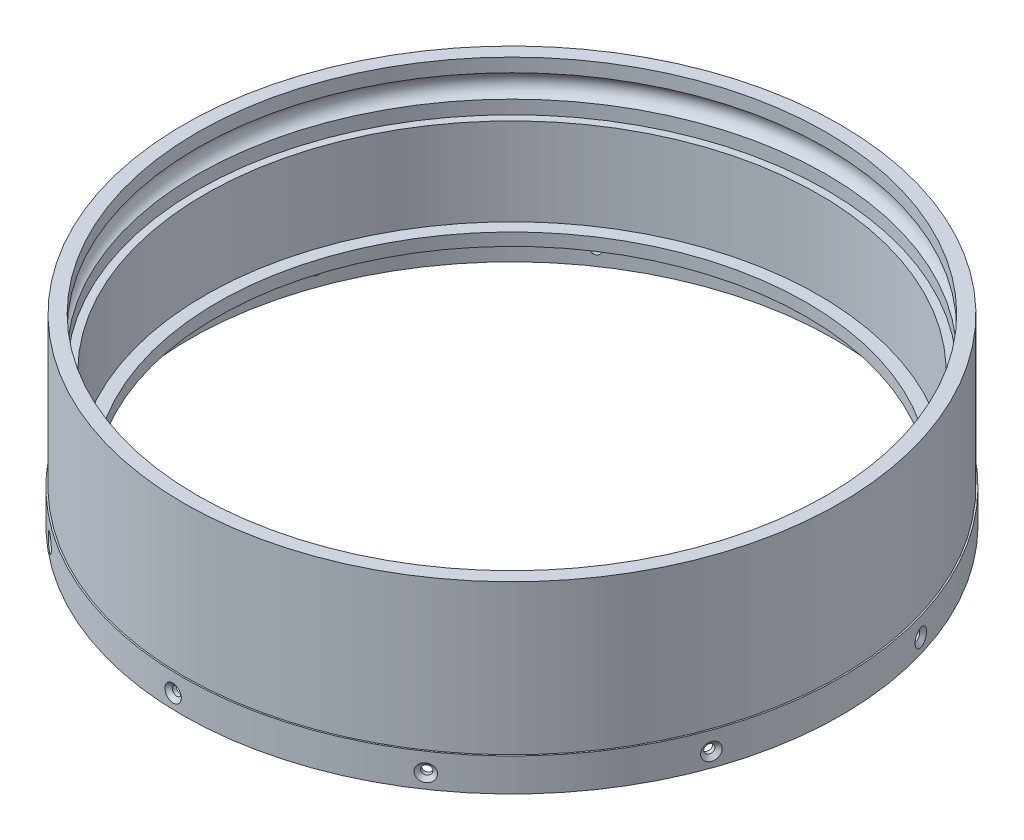
from build123d import *

# Parameters (mm, degrees)
CIRPATTERN1_COUNT = 10


with BuildPart() as part:
    # Sketch2 → Revolve1 (revolve)
    with BuildSketch(Plane(origin=(0, 0, 0), x_dir=(0, 0, -1), z_dir=(1, 0, 0))):
        with BuildLine():
            Line((79.99222, -2.192455674), (79.99222, -5.632520108))
            ThreePointArc((79.99222, -5.632520108), (81.89722, -8.542455674), (79.99222, -11.45239124))
            Line((79.99222, -11.45239124), (79.99222, -14.892455674))
            Line((79.99222, -14.892455674), (78.08722, -14.892455674))
            Line((78.08722, -14.892455674), (78.08722, -37.117455674))
            Line((78.08722, -37.117455674), (74.91222, -37.117455674))
            Line((74.91222, -37.117455674), (74.91222, -40.292455674))
            Line((74.91222, -40.292455674), (81.9531, -40.292455674))
            Line((81.9531, -40.292455674), (81.9531, -48.674455674))
            Line((81.9531, -48.674455674), (83.82, -48.674455674))
            Line((83.82, -48.674455674), (83.82, -40.292455674))
            Line((83.82, -40.292455674), (83.439, -40.292455674))
            Line((83.439, -40.292455674), (83.439, -2.192455674))
            Line((83.439, -2.192455674), (79.99222, -2.192455674))
        make_face()
    revolve(axis=Axis((0, 0, 0), (0, -1, 0)))

    # Sketch3 → CSK for #2 Flat Head Machine Screw (100)1 (revolve, cut)
    with BuildSketch(Plane(origin=(2.413258622, -45.008517513, -83.785252777), x_dir=(-0.999585454, 0, -0.028790964), z_dir=(0, 1, 0))):
        Polygon((0, 0), (0, 76.879152758), (1.1303, 76.2), (1.1303, 0.884494921), (2.1844, 0), align=None)
    csk_for_2_flat_head_machine_screw_100 = revolve(axis=Axis((2.596081245, -45.008517513, -90.132620411), (-0.028790964, 0, 0.999585454)), mode=Mode.SUBTRACT)

    # CirPattern1: CSK for #2 Flat Head Machine Screw (100)1 ×10 about axis
    cirpattern1_axis = Axis((0, 0, 0), (0, 1, 0))
    for i in range(1, CIRPATTERN1_COUNT):
        add(csk_for_2_flat_head_machine_screw_100.rotate(cirpattern1_axis, i * 360 / CIRPATTERN1_COUNT), mode=Mode.SUBTRACT)


solid = part.part
